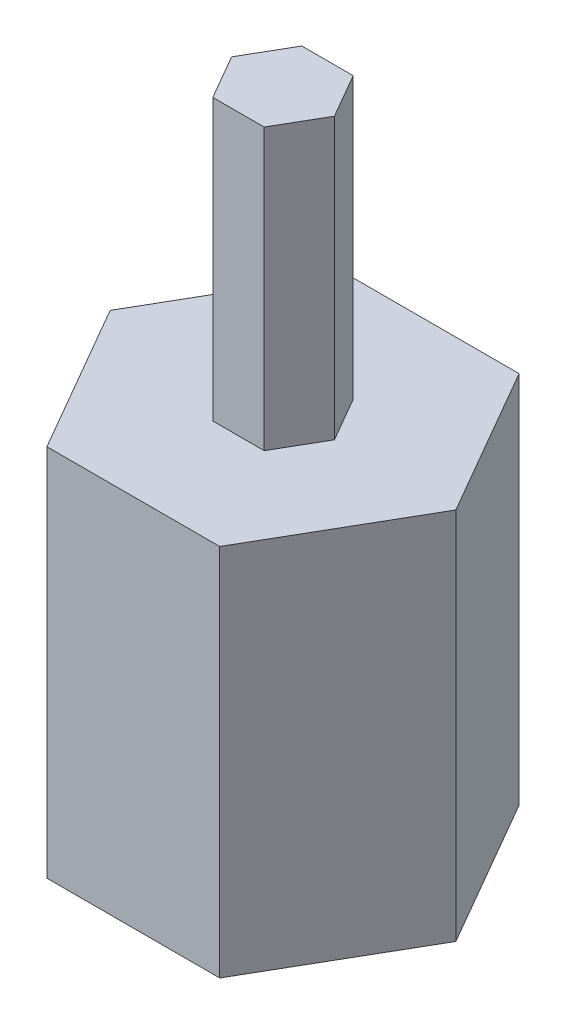
from build123d import *

# Parameters (mm, degrees)
BOSS_EXTRUDE1_DEPTH = 6
BOSS_EXTRUDE2_DEPTH = 8


with BuildPart() as part:
    # Sketch1 → Boss-Extrude1 (new body)
    with BuildSketch(Plane(origin=(0, 0, 0), x_dir=(1, 0, 0), z_dir=(0, 1, 0))):
        Polygon((1.1, 0), (0.55, 0.952627944), (-0.55, 0.952627944), (-1.1, 0), (-0.55, -0.952627944), (0.55, -0.952627944), align=None)
    extrude(amount=BOSS_EXTRUDE1_DEPTH)

    # Sketch2 → Boss-Extrude2 (add)
    with BuildSketch(Plane.XZ):
        Polygon((3.7, 0), (1.85, 3.204293994), (-1.85, 3.204293994), (-3.7, 0), (-1.85, -3.204293994), (1.85, -3.204293994), align=None)
    extrude(amount=BOSS_EXTRUDE2_DEPTH)


solid = part.part
